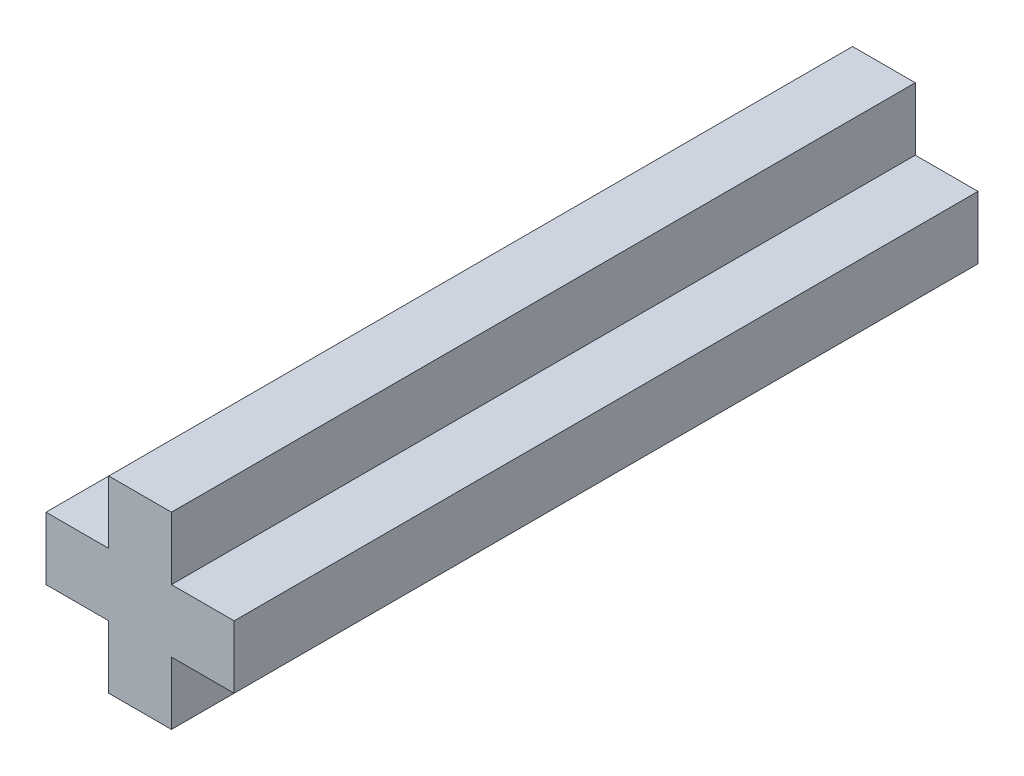
from build123d import *

# Parameters (mm, degrees)
BOSS_EXTRUDE1_DEPTH = 30


with BuildPart() as part:
    # Sketch1 → Boss-Extrude1 (new body)
    with BuildSketch(Plane.XY):
        Polygon((-3.794733192, 1.264911064), (-3.794733192, -1.264911064), (-1.264911064, -1.264911064), (-1.264911064, -3.794733192), (1.264911064, -3.794733192), (1.264911064, -1.264911064), (3.794733192, -1.264911064), (3.794733192, 1.264911064), (1.264911064, 1.264911064), (1.264911064, 3.794733192), (-1.264911064, 3.794733192), (-1.264911064, 1.264911064), align=None)
    extrude(amount=BOSS_EXTRUDE1_DEPTH)


solid = part.part
